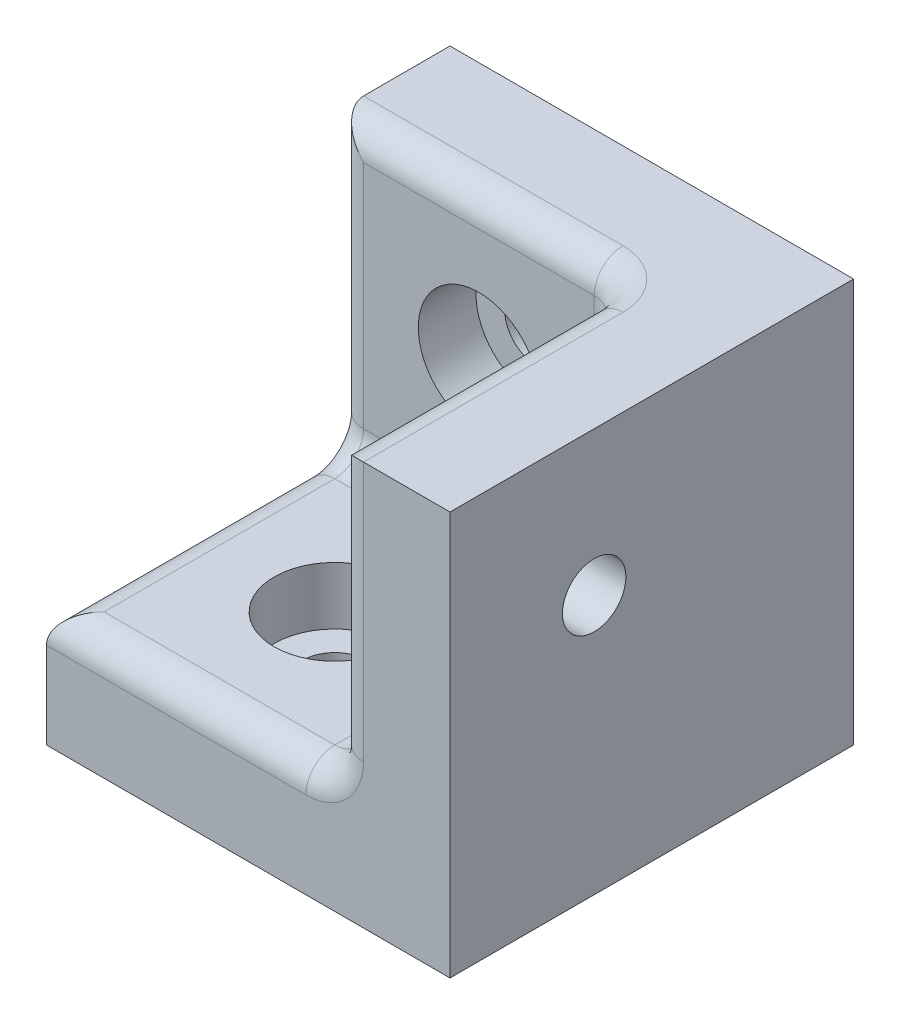
from build123d import *

# Parameters (mm, degrees)
ESQUISSE1_W             = 10
ESQUISSE1_H             = 14
BOSS_EXTRU_1_DEPTH      = 4
ESQUISSE2_W             = 10
ESQUISSE2_H             = 4
BOSS_EXTRU_2_DEPTH      = 10
ESQUISSE3_R             = 1.1
ENL_V_MAT_EXTRU_1_DEPTH = 5
ESQUISSE4_R             = 1.1
ENL_V_MAT_EXTRU_2_DEPTH = 5
ESQUISSE5_R             = 2.1
ENL_V_MAT_EXTRU_3_DEPTH = 2
ESQUISSE6_R             = 2.1
ENL_V_MAT_EXTRU_4_DEPTH = 2
ESQUISSE7_W             = 14
ESQUISSE7_H             = 14
BOSS_EXTRU_3_DEPTH      = 4
ESQUISSE8_R             = 1.1
ENL_V_MAT_EXTRU_5_DEPTH = 5
ESQUISSE9_R             = 2.1
ENL_V_MAT_EXTRU_6_DEPTH = 2
CONG_1_R                = 1


with BuildPart() as part:
    # Esquisse1 → Boss.-Extru.1 (new body)
    with BuildSketch(Plane.XY):
        with Locations((0, 7)):
            Rectangle(ESQUISSE1_W, ESQUISSE1_H)
    extrude(amount=BOSS_EXTRU_1_DEPTH)

    # Esquisse2 → Boss.-Extru.2 (add)
    with BuildSketch(Plane.XY.offset(4)):
        with Locations((0, 2)):
            Rectangle(ESQUISSE2_W, ESQUISSE2_H)
    extrude(amount=BOSS_EXTRU_2_DEPTH)

    # Esquisse3 → Enlèv. mat.-Extru.1 (cut, through all)
    with BuildSketch(Plane.XY.offset(4)):
        with Locations((0, 9)):
            Circle(ESQUISSE3_R)
    extrude(amount=-ENL_V_MAT_EXTRU_1_DEPTH, mode=Mode.SUBTRACT)

    # Esquisse4 → Enlèv. mat.-Extru.2 (cut, through all)
    with BuildSketch(Plane(origin=(0, 4, 0), x_dir=(1, 0, 0), z_dir=(0, 1, 0))):
        with Locations(Location((0, -9, 0), (0, 0, 270))):  # turned: the seam where the file's is
            Circle(ESQUISSE4_R)
    extrude(amount=-ENL_V_MAT_EXTRU_2_DEPTH, mode=Mode.SUBTRACT)

    # Esquisse5 → Enlèv. mat.-Extru.3 (cut)
    with BuildSketch(Plane.XY.offset(4)):
        with Locations((0, 9)):
            Circle(ESQUISSE5_R)
    extrude(amount=-ENL_V_MAT_EXTRU_3_DEPTH, mode=Mode.SUBTRACT)

    # Esquisse6 → Enlèv. mat.-Extru.4 (cut)
    with BuildSketch(Plane(origin=(0, 4, 0), x_dir=(1, 0, 0), z_dir=(0, 1, 0))):
        with Locations(Location((0, -9, 0), (0, 0, 270))):  # turned: the seam where the file's is
            Circle(ESQUISSE6_R)
    extrude(amount=-ENL_V_MAT_EXTRU_4_DEPTH, mode=Mode.SUBTRACT)

    # Esquisse7 → Boss.-Extru.3 (add)
    with BuildSketch(Plane(origin=(5, 0, 0), x_dir=(0, 0, -1), z_dir=(1, 0, 0))):
        with Locations((-7, 7)):
            Rectangle(ESQUISSE7_W, ESQUISSE7_H)
    extrude(amount=BOSS_EXTRU_3_DEPTH)

    # Esquisse8 → Enlèv. mat.-Extru.5 (cut, through all)
    with BuildSketch(Plane.ZY.offset(-5)):
        with Locations((9, 9)):
            Circle(ESQUISSE8_R)
    extrude(amount=-ENL_V_MAT_EXTRU_5_DEPTH, mode=Mode.SUBTRACT)

    # Esquisse9 → Enlèv. mat.-Extru.6 (cut)
    with BuildSketch(Plane.ZY.offset(-5)):
        with Locations((9, 9)):
            Circle(ESQUISSE9_R)
    extrude(amount=-ENL_V_MAT_EXTRU_6_DEPTH, mode=Mode.SUBTRACT)

    # Congé1
    cong_1_edges = [part.edges().sort_by_distance(p)[0] for p in [
        (5, 9, 4),
        (-5, 4, 9),
        (0, 4, 4),
        (5, 4, 9),
        (0, 14, 4),
        (0, 4, 14),
        (-5, 9, 4),
        (5, 14, 9),
        (5, 9, 14),
    ]]
    fillet(cong_1_edges, radius=CONG_1_R)


solid = part.part
